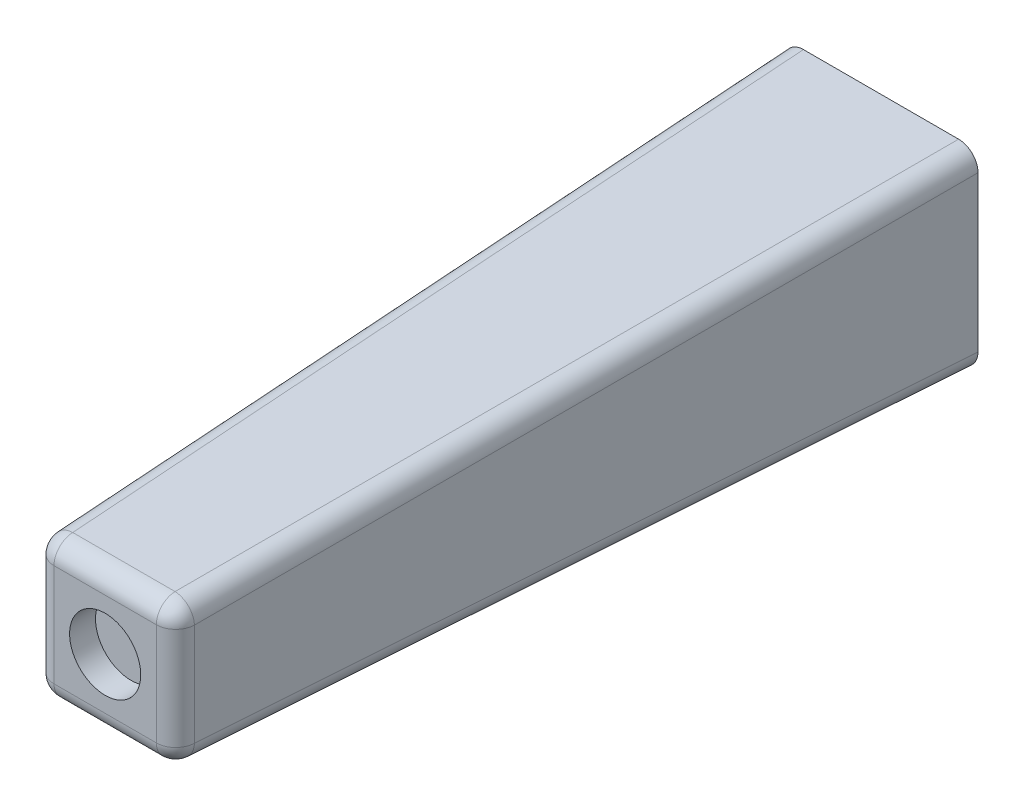
from build123d import *

# Parameters (mm, degrees)
SKETCH1_W           = 15
SKETCH1_H           = 15
BOSS_EXTRUDE1_DEPTH = 60
BOSS_EXTRUDE1_TAPER = 2
SKETCH2_R           = 1.5
CUT_EXTRUDE1_DEPTH  = 10
SKETCH3_R           = 2.75
CUT_EXTRUDE2_DEPTH  = 2
FILLET1_R           = 1.5


with BuildPart() as part:
    # Sketch1 → Boss-Extrude1 (new body)
    with BuildSketch(Plane.XY):
        Rectangle(SKETCH1_W, SKETCH1_H)
    extrude(amount=BOSS_EXTRUDE1_DEPTH, taper=BOSS_EXTRUDE1_TAPER)

    # Sketch2 → Cut-Extrude1 (cut)
    with BuildSketch(Plane(origin=(0, 0, 0), x_dir=(-1, 0, 0), z_dir=(0, 0, -1))):
        Circle(SKETCH2_R)
    extrude(amount=-CUT_EXTRUDE1_DEPTH, mode=Mode.SUBTRACT)

    # Sketch3 → Cut-Extrude2 (cut)
    with BuildSketch(Plane.XY.offset(60)):
        Circle(SKETCH3_R)
    extrude(amount=-CUT_EXTRUDE2_DEPTH, mode=Mode.SUBTRACT)

    # Fillet1
    fillet1_edges = [part.edges().sort_by_distance(p)[0] for p in [
        (-5.40475383, 0, 60),
        (0, -5.40475383, 60),
        (5.40475383, 0, 60),
        (6.452376915, -6.452376915, 30),
        (-6.452376915, -6.452376915, 30),
        (-6.452376453, 6.452376453, 30.000013228),
        (6.452376915, 6.452376915, 30),
        (0, 5.40475383, 60),
    ]]
    fillet(fillet1_edges, radius=FILLET1_R)


solid = part.part
